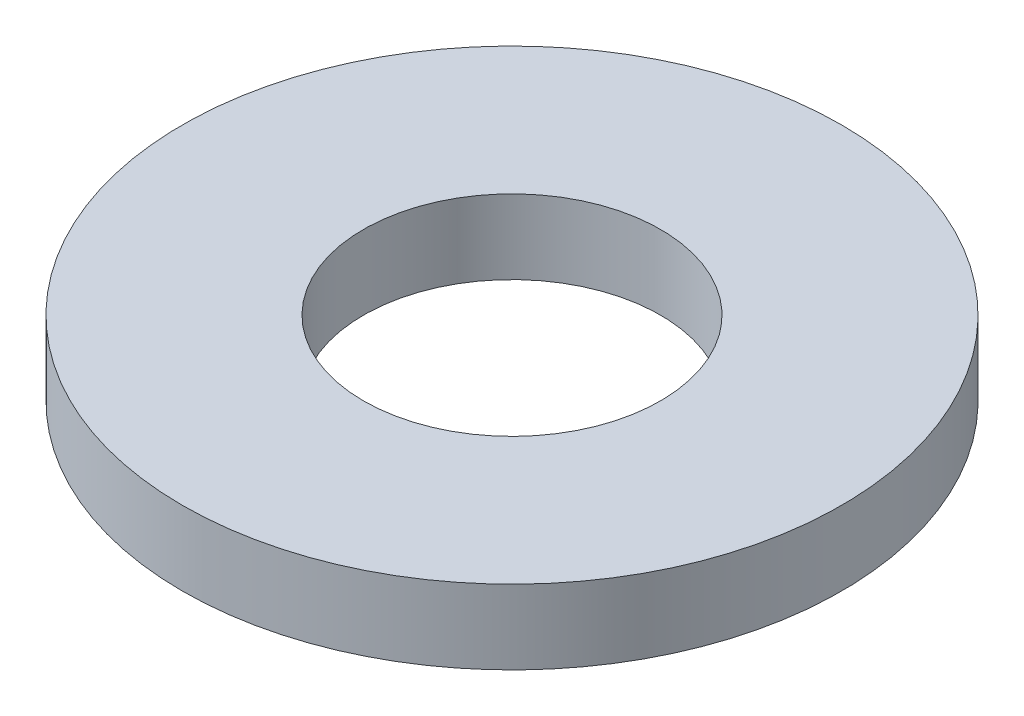
from build123d import *

# Parameters (mm, degrees)
SKETCH1_R           = 8.875
SKETCH1_R_2         = 4
BOSS_EXTRUDE1_DEPTH = 2


with BuildPart() as part:
    # Sketch1 → Boss-Extrude1 (new body)
    with BuildSketch(Plane(origin=(0, 0, 0), x_dir=(1, 0, 0), z_dir=(0, 1, 0))):
        Circle(SKETCH1_R)
        Circle(SKETCH1_R_2, mode=Mode.SUBTRACT)
    extrude(amount=BOSS_EXTRUDE1_DEPTH)


solid = part.part
